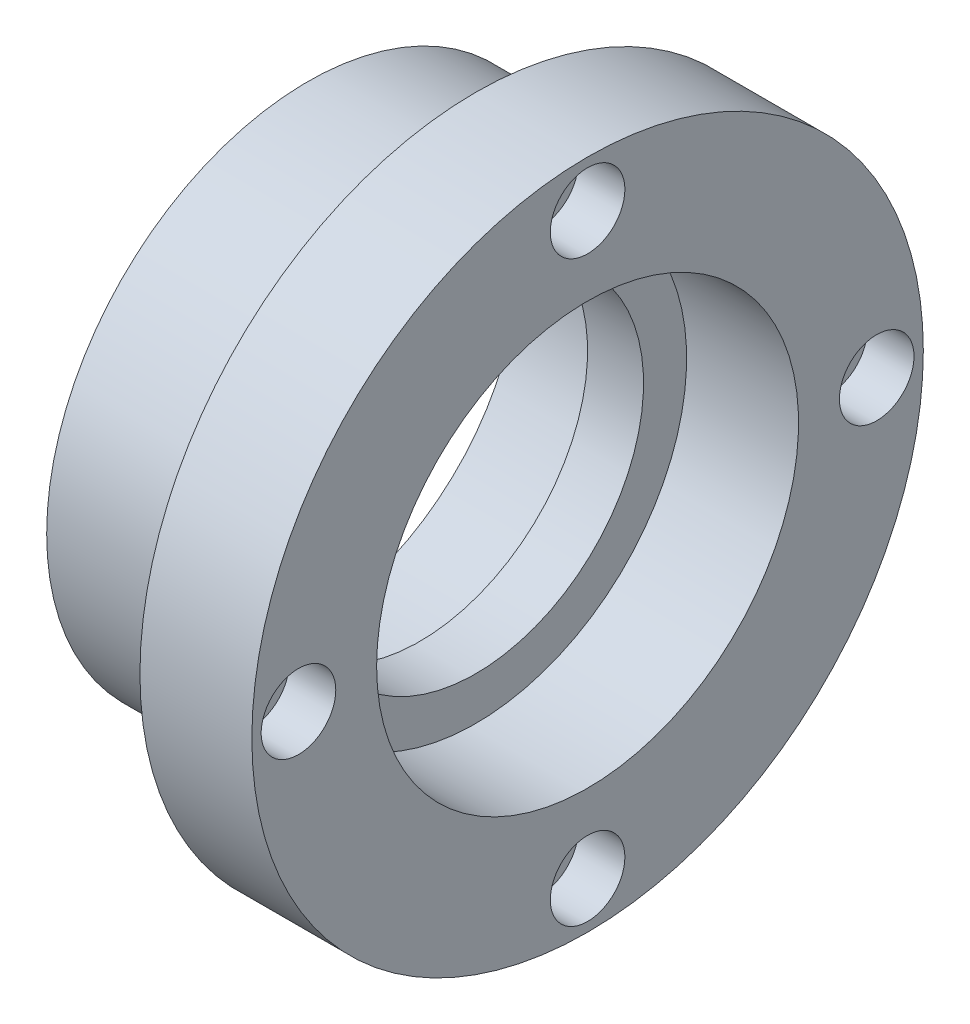
from build123d import *

# Parameters (mm, degrees)
CBORE_FOR_M4_SHCS1_D           = 4.5
CBORE_FOR_M4_SHCS1_CBORE_D     = 8
CBORE_FOR_M4_SHCS1_CBORE_DEPTH = 5
CIRPATTERN1_COUNT              = 4


with BuildPart() as part:
    # Sketch1 → Revolve1 (revolve)
    with BuildSketch(Plane.XY):
        Polygon((-30, 22.621875), (-18, 22.621875), (-18, 18), (-12, 18), (-12, 22.621875), (0, 22.621875), (0, 36), (-12, 36), (-12, 28), (-30, 28), align=None)
    revolve(axis=Axis((-59.7296875, 0, 0), (1, 0, 0)))

    # CBORE for M4 SHCS1 (through all)
    with Locations(Plane(origin=(0, 0, 0), x_dir=(0, 0, -1), z_dir=(1, 0, 0))):
        with Locations((0, 31)):
            cbore_for_m4_shcs1 = CounterBoreHole(CBORE_FOR_M4_SHCS1_D / 2, CBORE_FOR_M4_SHCS1_CBORE_D / 2, CBORE_FOR_M4_SHCS1_CBORE_DEPTH)

    # CirPattern1: CBORE for M4 SHCS1 ×4 about axis
    cirpattern1_axis = Axis((0, 0, 0), (1, 0, 0))
    for i in range(1, CIRPATTERN1_COUNT):
        add(cbore_for_m4_shcs1.rotate(cirpattern1_axis, i * 360 / CIRPATTERN1_COUNT), mode=Mode.SUBTRACT)


solid = part.part
